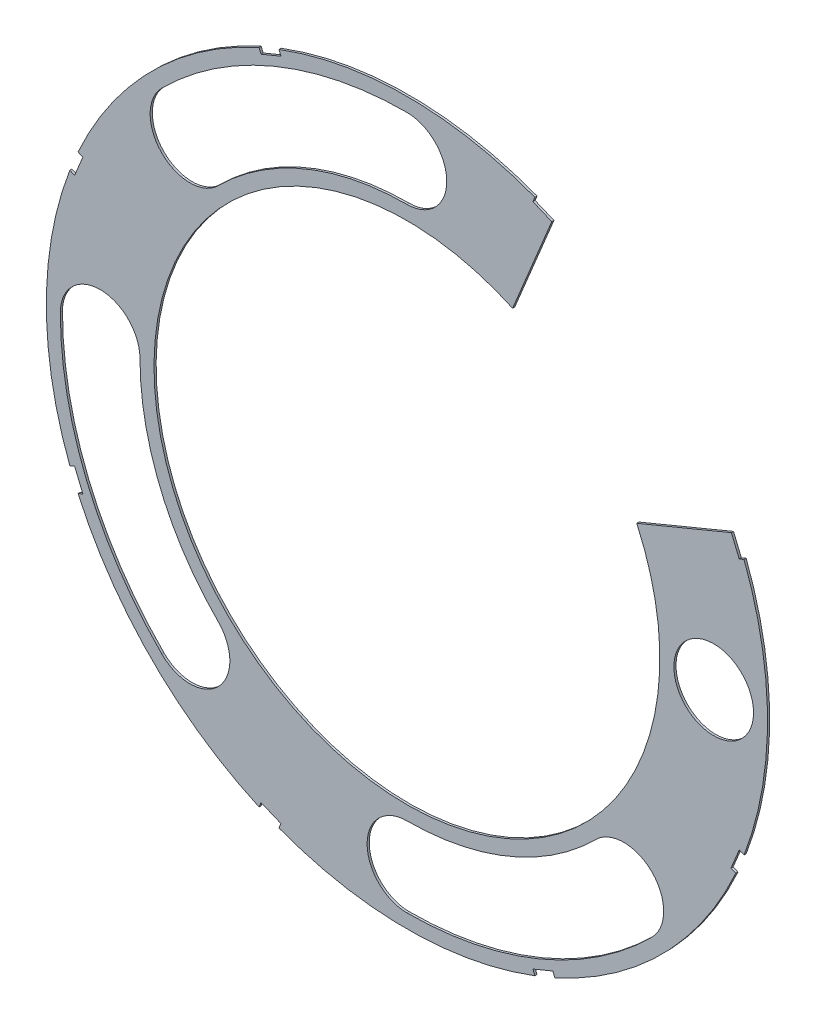
from build123d import *

# Parameters (mm, degrees)
SKETCH4_R           = 42.545
BOSS_EXTRUDE2_DEPTH = 0.254
SKETCH5_R           = 29.845
CUT_EXTRUDE5_DEPTH  = 1.254
SKETCH6_R           = 4.699
CUT_EXTRUDE6_DEPTH  = 1.254
CUT_EXTRUDE11_DEPTH = 1.254


with BuildPart() as part:
    # Sketch4 → Boss-Extrude2 (new body)
    with BuildSketch(Plane.XY):
        Circle(SKETCH4_R)
    extrude(amount=BOSS_EXTRUDE2_DEPTH)

    # Sketch5 → Cut-Extrude5 (cut, through all)
    with BuildSketch(Plane.XY.offset(0.254)):
        Circle(SKETCH5_R)
    extrude(amount=-CUT_EXTRUDE5_DEPTH, mode=Mode.SUBTRACT)

    # Sketch6 → Cut-Extrude6 (cut, through all)
    with BuildSketch(Plane.XY.offset(0.254)):
        with Locations((36.195, 0)):
            Circle(SKETCH6_R)
        with BuildLine():
            ThreePointArc((28.916424148, -28.916425271), (28.916424774, -22.271035245), (22.271034748, -22.271035613))
            ThreePointArc((22.271034748, -22.271035613), (12.052997339, -29.098509775), (5.1e-07, -31.496))
            ThreePointArc((5.1e-07, -31.496), (-4.699, -36.195000076), (6.62e-07, -40.894))
            ThreePointArc((6.62e-07, -40.894), (15.649456222, -37.781129628), (28.916424148, -28.916425271))
        make_face()
        with BuildLine():
            ThreePointArc((-28.916425271, -28.916424148), (-22.271035245, -28.916424774), (-22.271035613, -22.271034748))
            ThreePointArc((-22.271035613, -22.271034748), (-29.098509775, -12.052997339), (-31.496, -5.1e-07))
            ThreePointArc((-31.496, -5.1e-07), (-36.195000076, 4.699), (-40.894, -6.62e-07))
            ThreePointArc((-40.894, -6.62e-07), (-37.781129628, -15.649456222), (-28.916425271, -28.916424148))
        make_face()
        with BuildLine():
            ThreePointArc((-28.916424148, 28.916425271), (-28.916424774, 22.271035245), (-22.271034748, 22.271035613))
            ThreePointArc((-22.271034748, 22.271035613), (-12.052997339, 29.098509775), (-5.1e-07, 31.496))
            ThreePointArc((-5.1e-07, 31.496), (4.699, 36.195000076), (-6.62e-07, 40.894))
            ThreePointArc((-6.62e-07, 40.894), (-15.649456222, 37.781129628), (-28.916424148, 28.916425271))
        make_face()
    extrude(amount=-CUT_EXTRUDE6_DEPTH, mode=Mode.SUBTRACT)

    # Sketch8 → Cut-Extrude11 (cut, through all)
    with BuildSketch(Plane.XY.offset(0.254)):
        with BuildLine():
            Line((39.205799167, 14.864935644), (38.282384044, 17.094256956))
            Line((38.282384044, 17.094256956), (27.115548897, 12.468802389))
            ThreePointArc((27.115548897, 12.468802389), (21.103601885, 21.103601885), (12.468802389, 27.115548897))
            Line((12.468802389, 27.115548897), (17.094256956, 38.282384044))
            Line((17.094256956, 38.282384044), (14.864935644, 39.205799167))
            Line((14.864935644, 39.205799167), (15.107939624, 39.79246267))
            Line((15.107939624, 39.79246267), (16.28126663, 39.306454711))
            ThreePointArc((16.28126663, 39.306454711), (30.083858006, 30.083858006), (39.306454711, 16.28126663))
            Line((39.306454711, 16.28126663), (39.79246267, 15.107939624))
            Line((39.79246267, 15.107939624), (39.205799167, 14.864935644))
        make_face()
        Polygon((-15.350943603, 40.379126173), (-17.697597616, 39.407110255), (-17.211589657, 38.233783248), (-14.864935644, 39.205799167), align=None)
        Polygon((-39.407110255, 17.697597616), (-40.379126173, 15.350943603), (-39.205799167, 14.864935644), (-38.233783248, 17.211589657), align=None)
        Polygon((-40.379126173, -15.350943603), (-39.407110255, -17.697597616), (-38.233783248, -17.211589657), (-39.205799167, -14.864935644), align=None)
        Polygon((-17.697597616, -39.407110255), (-15.350943603, -40.379126173), (-14.864935644, -39.205799167), (-17.211589657, -38.233783248), align=None)
        Polygon((15.350943603, -40.379126173), (17.697597616, -39.407110255), (17.211589657, -38.233783248), (14.864935644, -39.205799167), align=None)
        Polygon((39.407110255, -17.697597616), (40.379126173, -15.350943603), (39.205799167, -14.864935644), (38.233783248, -17.211589657), align=None)
    extrude(amount=-CUT_EXTRUDE11_DEPTH, mode=Mode.SUBTRACT)


solid = part.part
